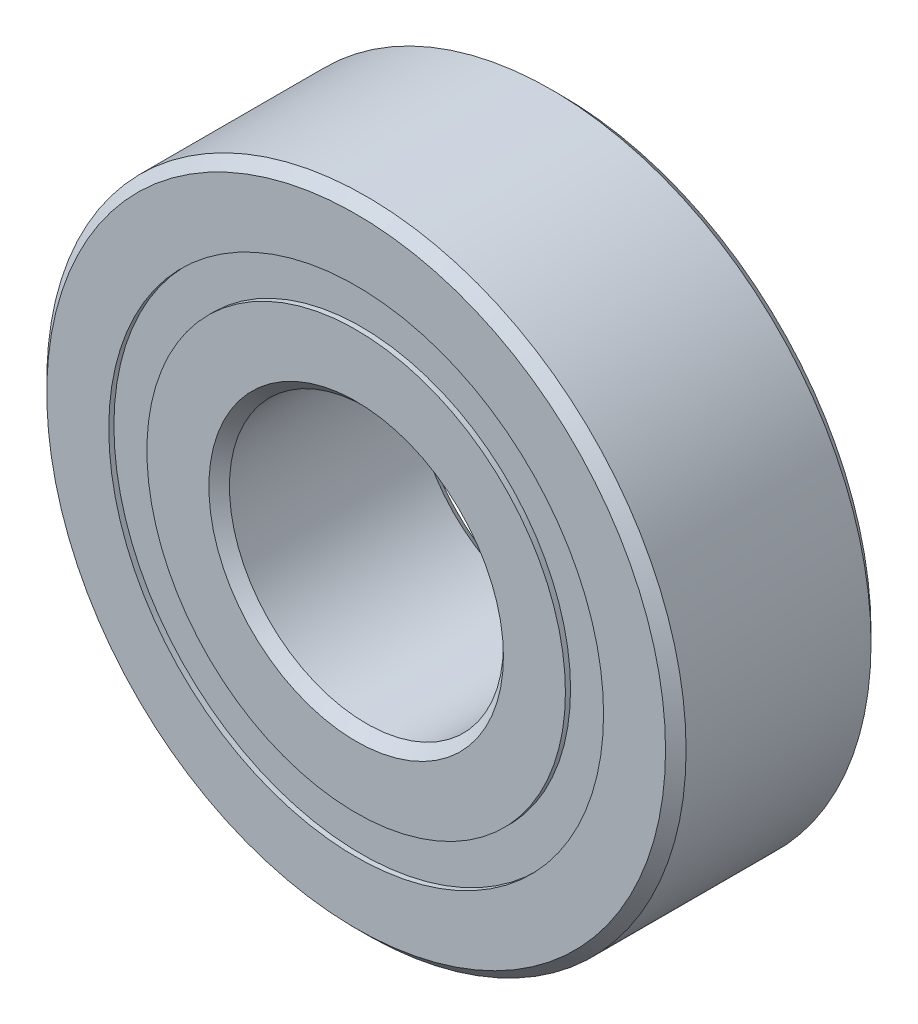
from build123d import *

# Parameters (mm, degrees)
CIRPATTERN1_COUNT = 12
SKETCH5_W         = 1.672929924
SKETCH5_H         = 1.325824176


with BuildPart() as part:
    # Sketch1 → Revolve1 (revolve)
    with BuildSketch(Plane(origin=(0, 0, 0), x_dir=(0, 0, -1), z_dir=(1, 0, 0))):
        with BuildLine():
            Line((3.2146875, 11.1125), (-3.2146875, 11.1125))
            Line((-3.2146875, 11.1125), (-3.571875, 10.7553125))
            Line((-3.571875, 10.7553125), (-3.571875, 8.600412088))
            Line((-3.571875, 8.600412088), (-1.5875, 8.600412088))
            ThreePointArc((-1.5875, 8.600412088), (0, 9.657851326), (1.5875, 8.600412088))
            Line((1.5875, 8.600412088), (3.571875, 8.600412088))
            Line((3.571875, 8.600412088), (3.571875, 10.7553125))
            Line((3.571875, 10.7553125), (3.2146875, 11.1125))
        make_face()
    revolve(axis=Axis((0, 0, 3.571875), (0, 0, -1)))


with BuildPart() as body_2:
    # Sketch3 → Revolve3 (revolve)
    with BuildSketch(Plane(origin=(0, 0, 0), x_dir=(0, 0, -1), z_dir=(1, 0, 0))):
        with BuildLine():
            Line((-3.571875, 7.274587912), (-1.5875, 7.274587912))
            ThreePointArc((-1.5875, 7.274587912), (0, 6.217148674), (1.5875, 7.274587912))
            Line((1.5875, 7.274587912), (3.571875, 7.274587912))
            Line((3.571875, 7.274587912), (3.571875, 5.1196875))
            Line((3.571875, 5.1196875), (3.2146875, 4.7625))
            Line((3.2146875, 4.7625), (-3.2146875, 4.7625))
            Line((-3.2146875, 4.7625), (-3.571875, 5.1196875))
            Line((-3.571875, 5.1196875), (-3.571875, 7.274587912))
        make_face()
    revolve(axis=Axis((0, 0, 3.571875), (0, 0, -1)))


with BuildPart() as body_3:
    # Sketch4 → Revolve4 (revolve)
    with BuildSketch(Plane(origin=(0, 0, 0), x_dir=(0, 0, -1), z_dir=(1, 0, 0))):
        with BuildLine():
            Line((-1.720351326, 7.9375), (1.720351326, 7.9375))
            ThreePointArc((1.720351326, 7.9375), (0, 9.657851326), (-1.720351326, 7.9375))
        make_face()
    revolve(axis=Axis((0, 7.9375, 1.720351326), (0, 0, -1)))


with BuildPart() as cirpattern1_1:
    # CirPattern1: pattern copy
    add(body_3.part.rotate(Axis((0, 0, -3.571875), (0, 0, 1)), 1 * 360 / CIRPATTERN1_COUNT))


with BuildPart() as cirpattern1_2:
    # CirPattern1: pattern copy
    add(body_3.part.rotate(Axis((0, 0, -3.571875), (0, 0, 1)), 2 * 360 / CIRPATTERN1_COUNT))


with BuildPart() as cirpattern1_3:
    # CirPattern1: pattern copy
    add(body_3.part.rotate(Axis((0, 0, -3.571875), (0, 0, 1)), 3 * 360 / CIRPATTERN1_COUNT))


with BuildPart() as cirpattern1_4:
    # CirPattern1: pattern copy
    add(body_3.part.rotate(Axis((0, 0, -3.571875), (0, 0, 1)), 4 * 360 / CIRPATTERN1_COUNT))


with BuildPart() as cirpattern1_5:
    # CirPattern1: pattern copy
    add(body_3.part.rotate(Axis((0, 0, -3.571875), (0, 0, 1)), 5 * 360 / CIRPATTERN1_COUNT))


with BuildPart() as cirpattern1_6:
    # CirPattern1: pattern copy
    add(body_3.part.rotate(Axis((0, 0, -3.571875), (0, 0, 1)), 6 * 360 / CIRPATTERN1_COUNT))


with BuildPart() as cirpattern1_7:
    # CirPattern1: pattern copy
    add(body_3.part.rotate(Axis((0, 0, -3.571875), (0, 0, 1)), 7 * 360 / CIRPATTERN1_COUNT))


with BuildPart() as cirpattern1_8:
    # CirPattern1: pattern copy
    add(body_3.part.rotate(Axis((0, 0, -3.571875), (0, 0, 1)), 8 * 360 / CIRPATTERN1_COUNT))


with BuildPart() as cirpattern1_9:
    # CirPattern1: pattern copy
    add(body_3.part.rotate(Axis((0, 0, -3.571875), (0, 0, 1)), 9 * 360 / CIRPATTERN1_COUNT))


with BuildPart() as cirpattern1_10:
    # CirPattern1: pattern copy
    add(body_3.part.rotate(Axis((0, 0, -3.571875), (0, 0, 1)), 10 * 360 / CIRPATTERN1_COUNT))


with BuildPart() as cirpattern1_11:
    # CirPattern1: pattern copy
    add(body_3.part.rotate(Axis((0, 0, -3.571875), (0, 0, 1)), 11 * 360 / CIRPATTERN1_COUNT))


with BuildPart() as body_15:
    # Sketch5 → Revolve5 (revolve)
    with BuildSketch(Plane(origin=(0, 0, 0), x_dir=(0, 0, -1), z_dir=(1, 0, 0))):
        with Locations((-2.556816288, 7.9375)):
            Rectangle(SKETCH5_W, SKETCH5_H)
        with Locations((2.556816288, 7.9375)):
            Rectangle(SKETCH5_W, SKETCH5_H)
    revolve(axis=Axis((0, 0, 3.571875), (0, 0, -1)))


solid = Compound([part.part, body_2.part, body_3.part, cirpattern1_1.part, cirpattern1_2.part, cirpattern1_3.part, cirpattern1_4.part, cirpattern1_5.part, cirpattern1_6.part, cirpattern1_7.part, cirpattern1_8.part, cirpattern1_9.part, cirpattern1_10.part, cirpattern1_11.part, body_15.part])
